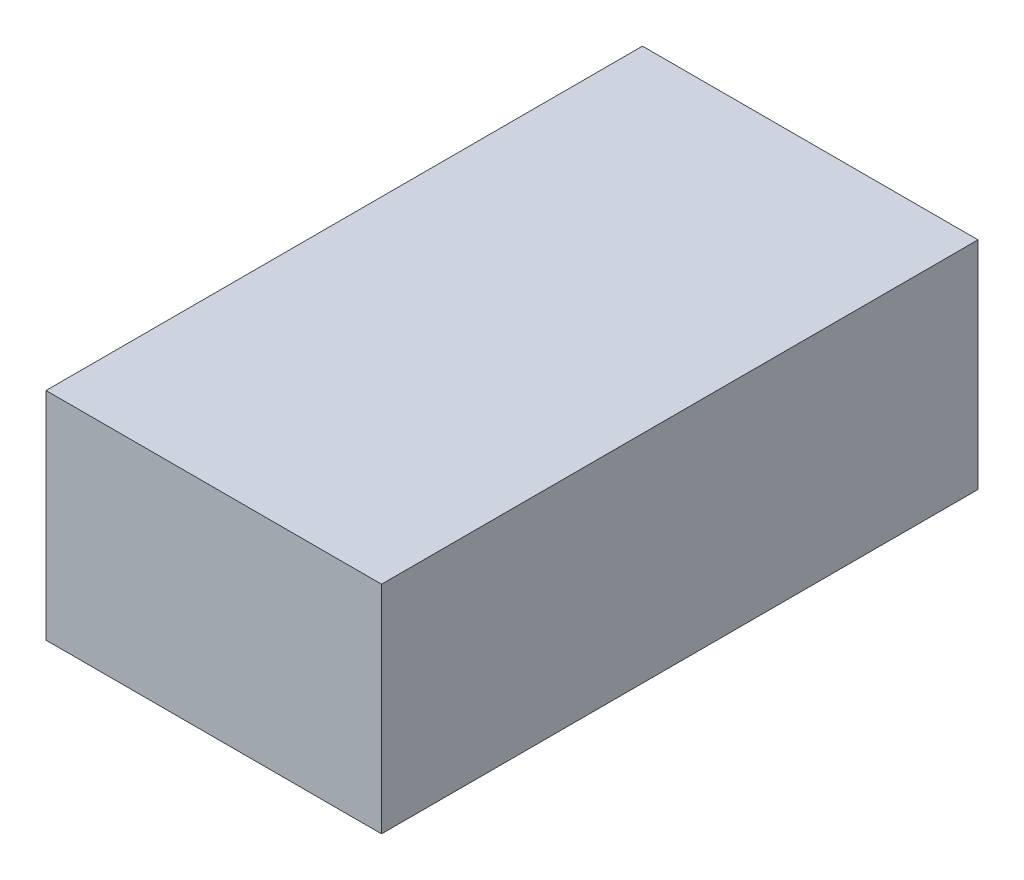
from build123d import *

# Parameters (mm, degrees)
SKETCH1_W           = 45
SKETCH1_H           = 80
BOSS_EXTRUDE1_DEPTH = 29


with BuildPart() as part:
    # Sketch1 → Boss-Extrude1 (new body)
    with BuildSketch(Plane(origin=(0, 0, 0), x_dir=(1, 0, 0), z_dir=(0, 1, 0))):
        Rectangle(SKETCH1_W, SKETCH1_H)
    extrude(amount=BOSS_EXTRUDE1_DEPTH)


solid = part.part
